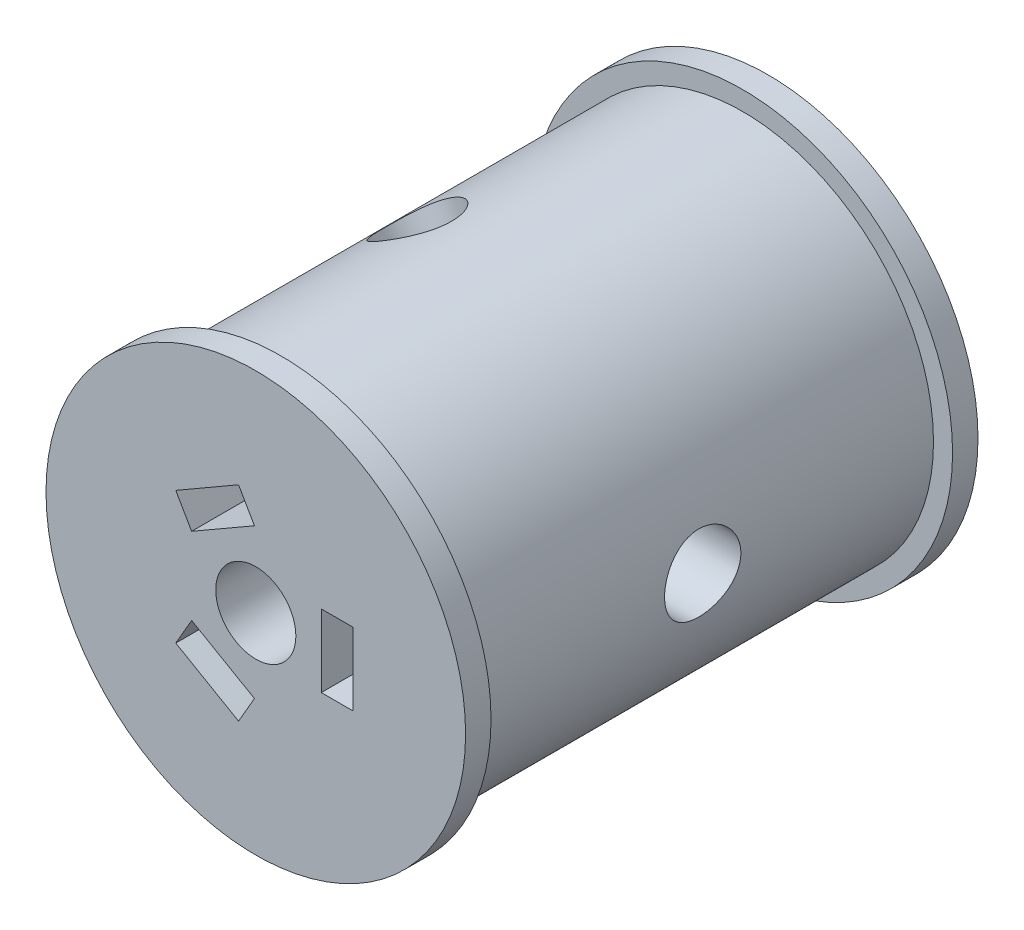
from build123d import *

# Parameters (mm, degrees)
SKETCH1_R           = 15
SKETCH1_R_2         = 3.15
BOSS_EXTRUDE1_DEPTH = 40.3
CUT_EXTRUDE1_DEPTH  = 23
CUT_EXTRUDE4_REACH  = 37.49
SKETCH8_R           = 1.65
CUT_EXTRUDE5_REACH  = 37.49
SKETCH10_R          = 1.65
SKETCH12_R          = 3
CUT_EXTRUDE6_DEPTH  = 5.35
SKETCH15_R          = 3
CUT_EXTRUDE8_DEPTH  = 5.35
CUT_EXTRUDE9_REACH  = 37.49
SKETCH17_R          = 1.65
CUT_EXTRUDE10_REACH = 37.49
SKETCH18_R          = 1.65
SKETCH19_R          = 3
CUT_EXTRUDE11_DEPTH = 5.35
CUT_EXTRUDE12_REACH = 32
SKETCH20_R          = 1.65
CUT_EXTRUDE13_REACH = 32
SKETCH21_R          = 1.65
SKETCH22_R          = 16.5
SKETCH22_R_2        = 3.15
SKETCH22_W          = 2.5
SKETCH22_H          = 5.7
BOSS_EXTRUDE3_DEPTH = 2
SKETCH23_R          = 16.5
SKETCH23_R_2        = 3.15
BOSS_EXTRUDE4_DEPTH = 2


with BuildPart() as part:
    # Sketch1 → Boss-Extrude1 (new body)
    with BuildSketch(Plane.XY):
        Circle(SKETCH1_R)
        Circle(SKETCH1_R_2, mode=Mode.SUBTRACT)
    extrude(amount=BOSS_EXTRUDE1_DEPTH)

    # Sketch2 → Cut-Extrude1 (cut)
    with BuildSketch(Plane.XY.offset(40.3)):
        Polygon((7.65, 0), (7.65, 2.85), (5.15, 2.85), (5.15, -2.85), (7.65, -2.85), align=None)
        Polygon((-3.825, -6.625094339), (-1.356827599, -8.050094339), (-0.106827599, -5.885030829), (-5.043172401, -3.035030829), (-6.293172401, -5.200094339), align=None)
        Polygon((-3.825, 6.625094339), (-6.293172401, 5.200094339), (-5.048242412, 3.035349353), (-0.105426694, 5.882604512), (-1.356827546, 8.050094369), align=None)
    extrude(amount=-CUT_EXTRUDE1_DEPTH, mode=Mode.SUBTRACT)

    # Sketch8 → Cut-Extrude4 (cut, up to next)
    with BuildSketch(Plane(origin=(-7.5, -12.990381057, 0), x_dir=(0, 0, -1), z_dir=(-0.5, -0.866025404, 0)), mode=Mode.PRIVATE) as cut_extrude4_sk1:
        with Locations((-20.15, 0)):
            Circle(SKETCH8_R)
    cut_extrude4_tool1 = extrude(cut_extrude4_sk1.sketch, amount=-CUT_EXTRUDE4_REACH, mode=Mode.PRIVATE) & part.part
    add(cut_extrude4_tool1.solids().sort_by_distance((-7.5, -12.990381, 20.15))[0], mode=Mode.SUBTRACT)

    # Sketch10 → Cut-Extrude5 (cut, up to next)
    with BuildSketch(Plane(origin=(-7.5, -12.990381057, 0), x_dir=(0, 0, -1), z_dir=(-0.5, -0.866025404, 0)), mode=Mode.PRIVATE) as cut_extrude5_sk1:
        with Locations((-20.15, 0)):
            Circle(SKETCH10_R)
    cut_extrude5_tool1 = extrude(cut_extrude5_sk1.sketch, amount=-CUT_EXTRUDE5_REACH, mode=Mode.PRIVATE) & part.part
    add(cut_extrude5_tool1.solids().sort_by_distance((-7.5, -12.990381, 20.15))[0], mode=Mode.SUBTRACT)

    # Sketch12 → Cut-Extrude6 (cut)
    with BuildSketch(Plane(origin=(-7.5, -12.990381057, 0), x_dir=(0, 0, -1), z_dir=(-0.5, -0.866025404, 0))):
        with Locations((-20.15, 0)):
            Circle(SKETCH12_R)
    extrude(amount=-CUT_EXTRUDE6_DEPTH, mode=Mode.SUBTRACT)

    # Sketch15 → Cut-Extrude8 (cut)
    with BuildSketch(Plane(origin=(-7.5, 12.990381057, 0), x_dir=(0, 0, -1), z_dir=(-0.5, 0.866025404, 0))):
        with Locations((-20.15, 0)):
            Circle(SKETCH15_R)
    extrude(amount=-CUT_EXTRUDE8_DEPTH, mode=Mode.SUBTRACT)

    # Sketch17 → Cut-Extrude9 (cut, up to next)
    with BuildSketch(Plane(origin=(-7.5, 12.990381057, 0), x_dir=(0, 0, -1), z_dir=(-0.5, 0.866025404, 0)), mode=Mode.PRIVATE) as cut_extrude9_sk1:
        with Locations((-20.15, 0)):
            Circle(SKETCH17_R)
    cut_extrude9_tool1 = extrude(cut_extrude9_sk1.sketch, amount=-CUT_EXTRUDE9_REACH, mode=Mode.PRIVATE) & part.part
    add(cut_extrude9_tool1.solids().sort_by_distance((-7.5, 12.990381, 20.15))[0], mode=Mode.SUBTRACT)

    # Sketch18 → Cut-Extrude10 (cut, up to next)
    with BuildSketch(Plane(origin=(-7.5, 12.990381057, 0), x_dir=(0, 0, -1), z_dir=(-0.5, 0.866025404, 0)), mode=Mode.PRIVATE) as cut_extrude10_sk1:
        with Locations((-20.15, 0)):
            Circle(SKETCH18_R)
    cut_extrude10_tool1 = extrude(cut_extrude10_sk1.sketch, amount=-CUT_EXTRUDE10_REACH, mode=Mode.PRIVATE) & part.part
    add(cut_extrude10_tool1.solids().sort_by_distance((-7.5, 12.990381, 20.15))[0], mode=Mode.SUBTRACT)

    # Sketch19 → Cut-Extrude11 (cut)
    with BuildSketch(Plane(origin=(15, 0, 0), x_dir=(0, 0, -1), z_dir=(1, 0, 0))):
        with Locations((-20.15, 0)):
            Circle(SKETCH19_R)
    extrude(amount=-CUT_EXTRUDE11_DEPTH, mode=Mode.SUBTRACT)

    # Sketch20 → Cut-Extrude12 (cut, up to next)
    with BuildSketch(Plane(origin=(15, 0, 0), x_dir=(0, 0, -1), z_dir=(1, 0, 0)), mode=Mode.PRIVATE) as cut_extrude12_sk1:
        with Locations((-20.15, 0)):
            Circle(SKETCH20_R)
    cut_extrude12_tool1 = extrude(cut_extrude12_sk1.sketch, amount=-CUT_EXTRUDE12_REACH, mode=Mode.PRIVATE) & part.part
    add(cut_extrude12_tool1.solids().sort_by_distance((15, 0, 20.15))[0], mode=Mode.SUBTRACT)

    # Sketch21 → Cut-Extrude13 (cut, up to next)
    with BuildSketch(Plane(origin=(15, 0, 0), x_dir=(0, 0, -1), z_dir=(1, 0, 0)), mode=Mode.PRIVATE) as cut_extrude13_sk1:
        with Locations((-20.15, 0)):
            Circle(SKETCH21_R)
    cut_extrude13_tool1 = extrude(cut_extrude13_sk1.sketch, amount=-CUT_EXTRUDE13_REACH, mode=Mode.PRIVATE) & part.part
    add(cut_extrude13_tool1.solids().sort_by_distance((15, 0, 20.15))[0], mode=Mode.SUBTRACT)

    # Sketch22 → Boss-Extrude3 (add)
    with BuildSketch(Plane.XY.offset(40.3)):
        Circle(SKETCH22_R)
        Circle(SKETCH22_R_2, mode=Mode.SUBTRACT)
        Polygon((-1.356827599, -8.050094339), (-0.106827599, -5.885030829), (-5.043172401, -3.035030829), (-6.293172401, -5.200094339), align=None, mode=Mode.SUBTRACT)
        with Locations((6.4, 0)):
            Rectangle(SKETCH22_W, SKETCH22_H, mode=Mode.SUBTRACT)
        Polygon((-5.048242412, 3.035349353), (-0.105426694, 5.882604512), (-1.356827546, 8.050094369), (-6.293172401, 5.200094339), align=None, mode=Mode.SUBTRACT)
    extrude(amount=-BOSS_EXTRUDE3_DEPTH)

    # Sketch23 → Boss-Extrude4 (add)
    with BuildSketch(Plane(origin=(0, 0, 0), x_dir=(-1, 0, 0), z_dir=(0, 0, -1))):
        Circle(SKETCH23_R)
        Circle(SKETCH23_R_2, mode=Mode.SUBTRACT)
    extrude(amount=-BOSS_EXTRUDE4_DEPTH)


solid = part.part
